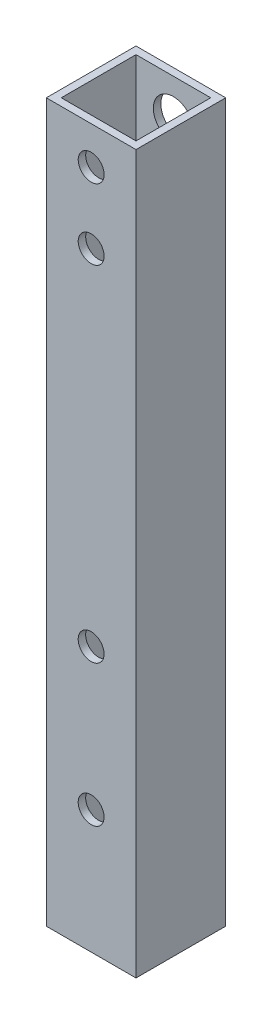
from build123d import *

# Parameters (mm, degrees)
SKETCH1_W           = 19.05
SKETCH1_H           = 19.05
SKETCH1_W_2         = 15.875
SKETCH1_H_2         = 15.875
BOSS_EXTRUDE1_DEPTH = 914.4
SKETCH2_R           = 2.75
CUT_EXTRUDE1_DEPTH  = 20.05
CUT_EXTRUDE2_REACH  = 21.05
SKETCH3_R           = 4.255
SKETCH4_W           = 19.05
SKETCH4_H           = 762
CUT_EXTRUDE3_DEPTH  = 20.05
SKETCH5_R           = 2.75
CUT_EXTRUDE4_DEPTH  = 20.05


with BuildPart() as part:
    # Sketch1 → Boss-Extrude1 (new body)
    with BuildSketch(Plane(origin=(0, 0, 0), x_dir=(1, 0, 0), z_dir=(0, 1, 0))):
        with Locations((9.525, 9.525)):
            Rectangle(SKETCH1_W, SKETCH1_H)
        with Locations((9.525, 9.525)):
            Rectangle(SKETCH1_W_2, SKETCH1_H_2, mode=Mode.SUBTRACT)
    extrude(amount=BOSS_EXTRUDE1_DEPTH)

    # Sketch2 → Cut-Extrude1 (cut, through all)
    with BuildSketch(Plane.XY):
        with Locations((9.525, 906.4)):
            Circle(SKETCH2_R)
        with Locations((9.525, 891.4)):
            Circle(SKETCH2_R)
    extrude(amount=-CUT_EXTRUDE1_DEPTH, mode=Mode.SUBTRACT)

    # Sketch3 → Cut-Extrude2 (cut, up to next)
    with BuildSketch(Plane(origin=(0, 0, -19.05), x_dir=(-1, 0, 0), z_dir=(0, 0, -1)), mode=Mode.PRIVATE) as cut_extrude2_sk1:
        with Locations((-9.525, 906.4)):
            Circle(SKETCH3_R)
    cut_extrude2_tool1 = extrude(cut_extrude2_sk1.sketch, amount=-CUT_EXTRUDE2_REACH, mode=Mode.PRIVATE) & part.part
    add(cut_extrude2_tool1.solids().sort_by_distance((9.525, 906.4, -19.05))[0], mode=Mode.SUBTRACT)
    # Sketch3 → Cut-Extrude2 (cut, up to next)
    with BuildSketch(Plane(origin=(0, 0, -19.05), x_dir=(-1, 0, 0), z_dir=(0, 0, -1)), mode=Mode.PRIVATE) as cut_extrude2_sk2:
        with Locations((-9.525, 891.4)):
            Circle(SKETCH3_R)
    cut_extrude2_tool2 = extrude(cut_extrude2_sk2.sketch, amount=-CUT_EXTRUDE2_REACH, mode=Mode.PRIVATE) & part.part
    add(cut_extrude2_tool2.solids().sort_by_distance((9.525, 891.4, -19.05))[0], mode=Mode.SUBTRACT)

    # Sketch4 → Cut-Extrude3 (cut, through all)
    with BuildSketch(Plane.XY):
        with Locations((9.525, 381)):
            Rectangle(SKETCH4_W, SKETCH4_H)
    extrude(amount=-CUT_EXTRUDE3_DEPTH, mode=Mode.SUBTRACT)

    # Sketch5 → Cut-Extrude4 (cut, through all)
    with BuildSketch(Plane.XY):
        with Locations((9.52, 788.2)):
            Circle(SKETCH5_R)
        with Locations((9.52, 818.2)):
            Circle(SKETCH5_R)
    extrude(amount=-CUT_EXTRUDE4_DEPTH, mode=Mode.SUBTRACT)


solid = part.part
